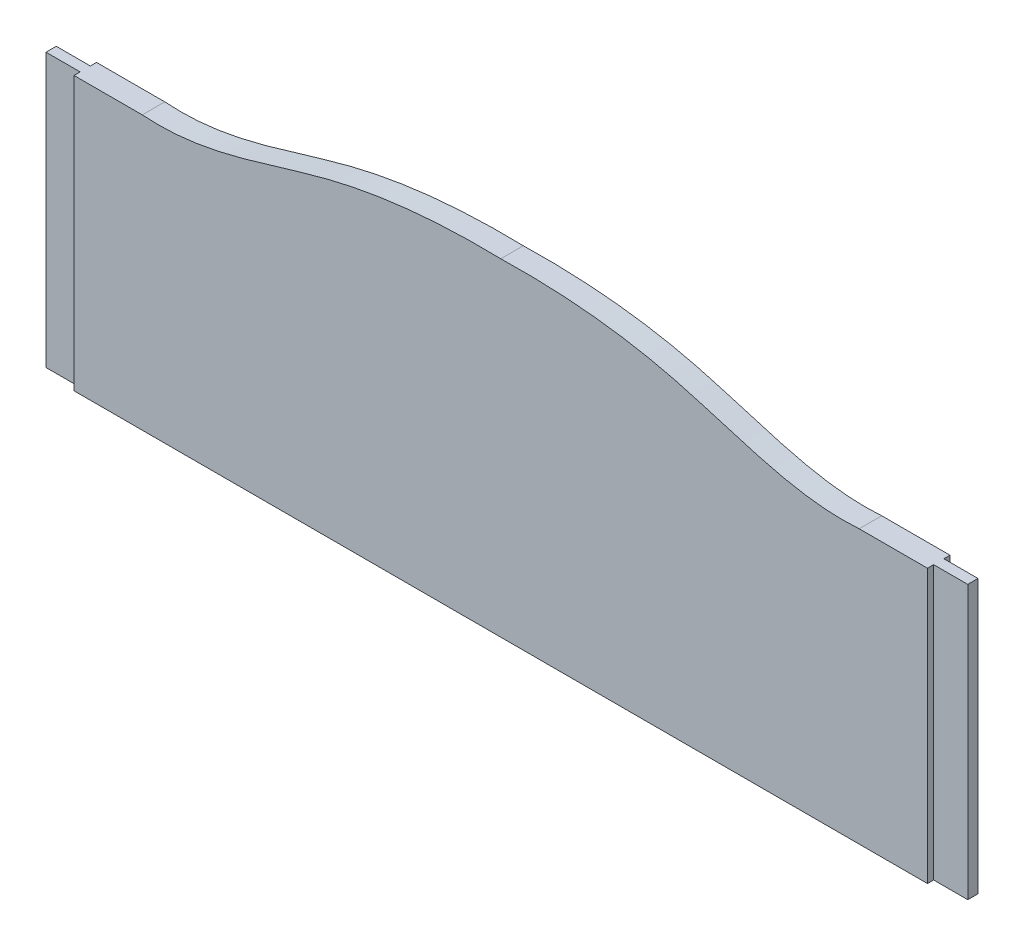
from build123d import *

# Parameters (mm, degrees)
BOSS_EXTRUDE1_DEPTH = 33
SKETCH2_W           = 50
SKETCH2_H           = 15
BOSS_EXTRUDE2_DEPTH = 400


with BuildPart() as part:
    # Sketch1 → Boss-Extrude1 (new body)
    with BuildSketch(Plane.XY):
        with BuildLine():
            Line((0, 0), (0, -480))
            Line((0, -480), (-625, -480))
            Line((-625, -480), (-625, -80))
            Line((-625, -80), (-525, -80))
            add(Edge.make_bspline(
                [(0, 0), (-83.701492577, 2.102656983), (-263.298331294, -12.316995698), (-428.0447482, -87.215369033), (-525, -80)],
                knots=[0, 0, 0, 0, 0.472195636, 1, 1, 1, 1], degree=3))
        make_face()
    boss_extrude1 = extrude(amount=BOSS_EXTRUDE1_DEPTH)

    # Sketch2 → Boss-Extrude2 (add, through all)
    with BuildSketch(Plane(origin=(0, -80, 0), x_dir=(1, 0, 0), z_dir=(0, 1, 0))):
        with Locations((-650, -16.5)):
            Rectangle(SKETCH2_W, SKETCH2_H)
    boss_extrude2 = extrude(amount=-BOSS_EXTRUDE2_DEPTH)

    # Mirror2: Boss-Extrude1, Boss-Extrude2 across plane
    add(boss_extrude1.mirror(Plane(origin=(0, 0, 0), x_dir=(0, 0, 1), z_dir=(1, 0, 0))))
    add(boss_extrude2.mirror(Plane(origin=(0, 0, 0), x_dir=(0, 0, 1), z_dir=(1, 0, 0))))


solid = part.part
